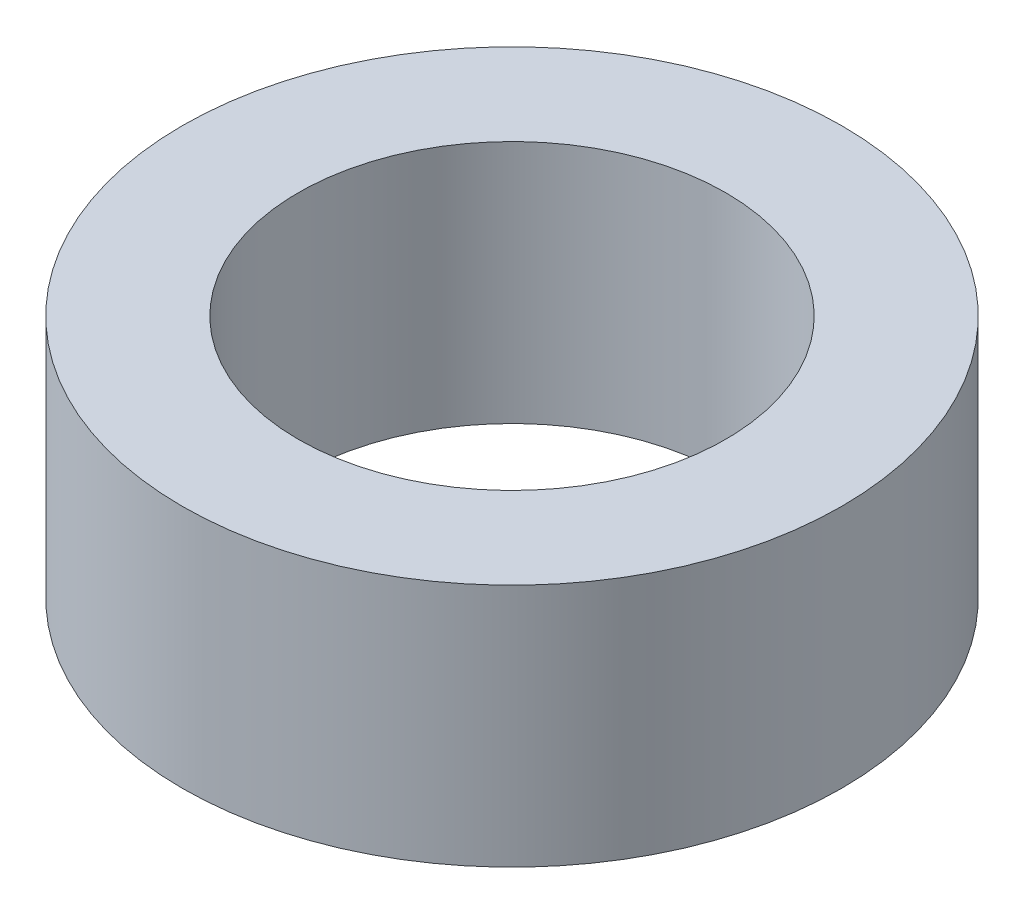
from build123d import *

# Parameters (mm, degrees)
SKETCH1_R           = 5.4
SKETCH1_R_2         = 3.5
BOSS_EXTRUDE1_DEPTH = 4


with BuildPart() as part:
    # Sketch1 → Boss-Extrude1 (new body)
    with BuildSketch(Plane(origin=(0, 0, 0), x_dir=(1, 0, 0), z_dir=(0, 1, 0))):
        Circle(SKETCH1_R)
        Circle(SKETCH1_R_2, mode=Mode.SUBTRACT)
    extrude(amount=BOSS_EXTRUDE1_DEPTH)


solid = part.part
